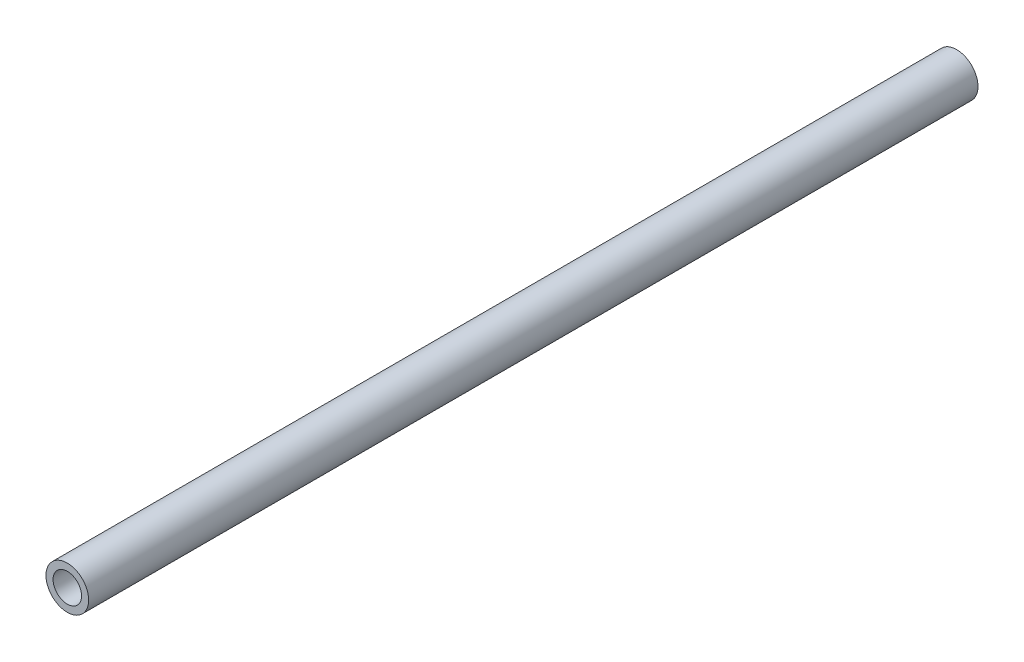
from build123d import *

# Parameters (mm, degrees)
SKETCH1_R           = 7.62
SKETCH1_R_2         = 5.08
BOSS_EXTRUDE1_DEPTH = 317.5


with BuildPart() as part:
    # Sketch1 → Boss-Extrude1 (new body)
    with BuildSketch(Plane.XY):
        Circle(SKETCH1_R)
        Circle(SKETCH1_R_2, mode=Mode.SUBTRACT)
    extrude(amount=BOSS_EXTRUDE1_DEPTH)


solid = part.part
